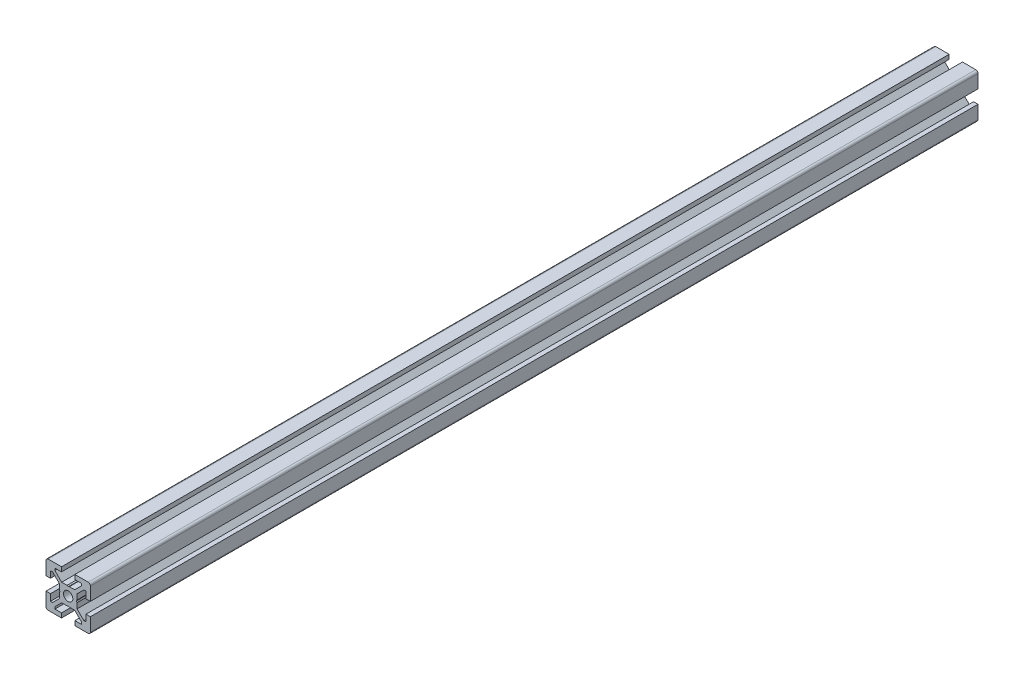
from build123d import *

# Parameters (mm, degrees)
SKETCH1_R                 = 2.1
BOSS_EXTRUDE1_DEPTH       = 400
M5X0_8_TAPPED_HOLE1_D     = 4.2
M5X0_8_TAPPED_HOLE1_DEPTH = 14
M5X0_8_TAPPED_HOLE1_TIP   = 1.2618073
M5X0_8_TAPPED_HOLE2_D     = 4.2
M5X0_8_TAPPED_HOLE2_DEPTH = 14
M5X0_8_TAPPED_HOLE2_TIP   = 1.2618073


with BuildPart() as part:
    # Sketch1 → Boss-Extrude1 (new body)
    with BuildSketch(Plane(origin=(0, 0, -400), x_dir=(-1, 0, 0), z_dir=(0, 0, -1))):
        with BuildLine():
            Line((10, -3), (8, -3))
            Line((8, -3), (8, -6))
            Line((8, -6), (7.060660172, -6))
            Line((7.060660172, -6), (4, -2.939339828))
            Line((4, -2.939339828), (4, -0.519615242))
            Line((4, -0.519615242), (3.7, 0))
            Line((3.7, 0), (4, 0.519615242))
            Line((4, 0.519615242), (4, 2.939339828))
            Line((4, 2.939339828), (7.060660172, 6))
            Line((7.060660172, 6), (8, 6))
            Line((8, 6), (8, 3))
            Line((8, 3), (10, 3))
            Line((10, 3), (10, 9))
            ThreePointArc((10, 9), (9.707106781, 9.707106781), (9, 10))
            Line((9, 10), (3, 10))
            Line((3, 10), (3, 8))
            Line((3, 8), (6, 8))
            Line((6, 8), (6, 7.060660172))
            Line((6, 7.060660172), (2.939339828, 4))
            Line((2.939339828, 4), (0.519615242, 4))
            Line((0.519615242, 4), (0, 3.7))
            Line((0, 3.7), (-0.519615242, 4))
            Line((-0.519615242, 4), (-2.939339828, 4))
            Line((-2.939339828, 4), (-6, 7.060660172))
            Line((-6, 7.060660172), (-6, 8))
            Line((-6, 8), (-3, 8))
            Line((-3, 8), (-3, 10))
            Line((-3, 10), (-9, 10))
            ThreePointArc((-9, 10), (-9.707106781, 9.707106781), (-10, 9))
            Line((-10, 9), (-10, 3))
            Line((-10, 3), (-8, 3))
            Line((-8, 3), (-8, 6))
            Line((-8, 6), (-7.060660172, 6))
            Line((-7.060660172, 6), (-4, 2.939339828))
            Line((-4, 2.939339828), (-4, 0.519615242))
            Line((-4, 0.519615242), (-3.7, 0))
            Line((-3.7, 0), (-4, -0.519615242))
            Line((-4, -0.519615242), (-4, -2.939339828))
            Line((-4, -2.939339828), (-7.060660172, -6))
            Line((-7.060660172, -6), (-8, -6))
            Line((-8, -6), (-8, -3))
            Line((-8, -3), (-10, -3))
            Line((-10, -3), (-10, -9))
            ThreePointArc((-10, -9), (-9.707106781, -9.707106781), (-9, -10))
            Line((-9, -10), (-3, -10))
            Line((-3, -10), (-3, -8))
            Line((-3, -8), (-6, -8))
            Line((-6, -8), (-6, -7.060660172))
            Line((-6, -7.060660172), (-2.939339828, -4))
            Line((-2.939339828, -4), (-0.519615242, -4))
            Line((-0.519615242, -4), (0, -3.7))
            Line((0, -3.7), (0.519615242, -4))
            Line((0.519615242, -4), (2.939339828, -4))
            Line((2.939339828, -4), (6, -7.060660172))
            Line((6, -7.060660172), (6, -8))
            Line((6, -8), (3, -8))
            Line((3, -8), (3, -10))
            Line((3, -10), (9, -10))
            ThreePointArc((9, -10), (9.707106781, -9.707106781), (10, -9))
            Line((10, -9), (10, -3))
        make_face()
        Circle(SKETCH1_R, mode=Mode.SUBTRACT)
    extrude(amount=-BOSS_EXTRUDE1_DEPTH)

    # M5x0.8 Tapped Hole1
    with Locations(Plane.XY):
        with Locations((0, 0)):
            Hole(M5X0_8_TAPPED_HOLE1_D / 2, depth=M5X0_8_TAPPED_HOLE1_DEPTH)
            with Locations((0, 0, -(M5X0_8_TAPPED_HOLE1_DEPTH + M5X0_8_TAPPED_HOLE1_TIP / 2))):  # 118° drill point
                Cone(0, M5X0_8_TAPPED_HOLE1_D / 2, M5X0_8_TAPPED_HOLE1_TIP, mode=Mode.SUBTRACT)

    # M5x0.8 Tapped Hole2
    with Locations(Plane(origin=(0, 0, -400), x_dir=(-1, 0, 0), z_dir=(0, 0, -1))):
        with Locations((0, 0)):
            Hole(M5X0_8_TAPPED_HOLE2_D / 2, depth=M5X0_8_TAPPED_HOLE2_DEPTH)
            with Locations((0, 0, -(M5X0_8_TAPPED_HOLE2_DEPTH + M5X0_8_TAPPED_HOLE2_TIP / 2))):  # 118° drill point
                Cone(0, M5X0_8_TAPPED_HOLE2_D / 2, M5X0_8_TAPPED_HOLE2_TIP, mode=Mode.SUBTRACT)


solid = part.part
